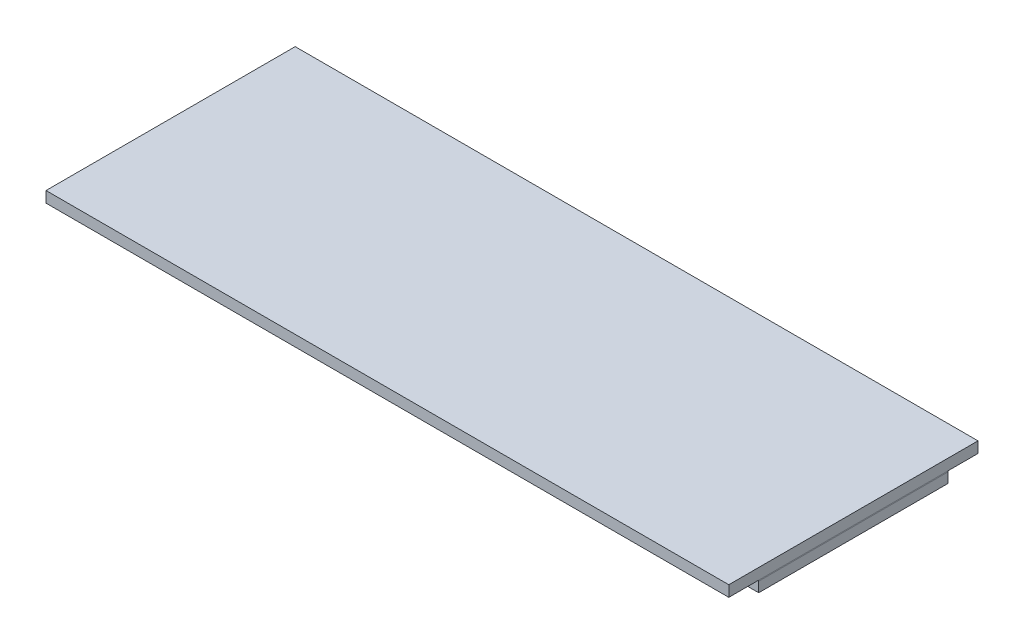
from build123d import *

# Parameters (mm, degrees)
SKETCH1_W           = 68.5
SKETCH1_H           = 25
BOSS_EXTRUDE1_DEPTH = 1.1
SKETCH2_W           = 68.5
SKETCH2_H           = 19
BOSS_EXTRUDE2_DEPTH = 0.1
SKETCH6_W           = 0.51
SKETCH6_H           = 0.5
F_16X2_LCD_DEPTH    = 1
SKETCH7_W           = 0.51
SKETCH7_H           = 0.5
DISPLAY_DEPTH       = 1
SKETCH4_W           = 68.5
SKETCH4_H           = 19
BOSS_EXTRUDE3_DEPTH = 1


with BuildPart() as part:
    # Sketch1 → Boss-Extrude1 (new body)
    with BuildSketch(Plane(origin=(0, 0, 0), x_dir=(1, 0, 0), z_dir=(0, 1, 0))):
        Rectangle(SKETCH1_W, SKETCH1_H)
    extrude(amount=BOSS_EXTRUDE1_DEPTH)


with BuildPart() as body_2:
    # Sketch2 → Boss-Extrude2 (new body)
    with BuildSketch(Plane(origin=(0, 0, 0), x_dir=(1, 0, 0), z_dir=(0, 1, 0))):
        Rectangle(SKETCH2_W, SKETCH2_H)
    extrude(amount=-BOSS_EXTRUDE2_DEPTH)

    # Sketch6 → 16x2 LCD (cut)
    with BuildSketch(Plane(origin=(0, 0, 0), x_dir=(1, 0, 0), z_dir=(0, 1, 0))):
        with Locations((-27.375, -0.65)):
            Rectangle(SKETCH6_W, SKETCH6_H)
        with Locations((-27.375, -1.2)):
            Rectangle(SKETCH6_W, SKETCH6_H)
        with Locations((-27.375, -1.75)):
            Rectangle(SKETCH6_W, SKETCH6_H)
        with Locations((-27.375, -2.3)):
            Rectangle(SKETCH6_W, SKETCH6_H)
        with Locations((-27.375, -2.85)):
            Rectangle(SKETCH6_W, SKETCH6_H)
        with Locations((-27.375, -3.4)):
            Rectangle(SKETCH6_W, SKETCH6_H)
        with Locations((-27.375, -3.95)):
            Rectangle(SKETCH6_W, SKETCH6_H)
        with Locations((-27.985, -3.95)):
            Rectangle(SKETCH6_W, SKETCH6_H)
        with Locations((-26.765, -3.95)):
            Rectangle(SKETCH6_W, SKETCH6_H)
        with Locations((-27.985, -1.2)):
            Rectangle(SKETCH6_W, SKETCH6_H)
        with Locations((-22.505, -2.85)):
            Rectangle(SKETCH6_W, SKETCH6_H)
        with Locations((-22.505, -3.4)):
            Rectangle(SKETCH6_W, SKETCH6_H)
        with Locations((-23.115, -3.95)):
            Rectangle(SKETCH6_W, SKETCH6_H)
        with Locations((-23.725, -3.95)):
            Rectangle(SKETCH6_W, SKETCH6_H)
        with Locations((-24.335, -3.95)):
            Rectangle(SKETCH6_W, SKETCH6_H)
        with Locations((-24.945, -3.4)):
            Rectangle(SKETCH6_W, SKETCH6_H)
        with Locations((-24.945, -2.85)):
            Rectangle(SKETCH6_W, SKETCH6_H)
        with Locations((-24.945, -2.3)):
            Rectangle(SKETCH6_W, SKETCH6_H)
        with Locations((-23.115, -0.65)):
            Rectangle(SKETCH6_W, SKETCH6_H)
        with Locations((-23.725, -0.65)):
            Rectangle(SKETCH6_W, SKETCH6_H)
        with Locations((-24.335, -1.2)):
            Rectangle(SKETCH6_W, SKETCH6_H)
        with Locations((-24.945, -1.75)):
            Rectangle(SKETCH6_W, SKETCH6_H)
        with Locations((-24.335, -2.3)):
            Rectangle(SKETCH6_W, SKETCH6_H)
        with Locations((-23.725, -2.3)):
            Rectangle(SKETCH6_W, SKETCH6_H)
        with Locations((-23.115, -2.3)):
            Rectangle(SKETCH6_W, SKETCH6_H)
        with Locations((-21.295, -3.95)):
            Rectangle(SKETCH6_W, SKETCH6_H)
        with Locations((-20.685, -3.4)):
            Rectangle(SKETCH6_W, SKETCH6_H)
        with Locations((-20.075, -2.85)):
            Rectangle(SKETCH6_W, SKETCH6_H)
        with Locations((-19.465, -2.3)):
            Rectangle(SKETCH6_W, SKETCH6_H)
        with Locations((-18.855, -1.75)):
            Rectangle(SKETCH6_W, SKETCH6_H)
        with Locations((-20.685, -2.3)):
            Rectangle(SKETCH6_W, SKETCH6_H)
        with Locations((-21.295, -1.75)):
            Rectangle(SKETCH6_W, SKETCH6_H)
        with Locations((-19.465, -3.4)):
            Rectangle(SKETCH6_W, SKETCH6_H)
        with Locations((-18.855, -3.95)):
            Rectangle(SKETCH6_W, SKETCH6_H)
        with Locations((-17.035, -0.65)):
            Rectangle(SKETCH6_W, SKETCH6_H)
        with Locations((-16.425, -0.65)):
            Rectangle(SKETCH6_W, SKETCH6_H)
        with Locations((-15.815, -0.65)):
            Rectangle(SKETCH6_W, SKETCH6_H)
        with Locations((-15.205, -1.2)):
            Rectangle(SKETCH6_W, SKETCH6_H)
        with Locations((-15.205, -1.75)):
            Rectangle(SKETCH6_W, SKETCH6_H)
        with Locations((-15.815, -2.3)):
            Rectangle(SKETCH6_W, SKETCH6_H)
        with Locations((-16.425, -2.85)):
            Rectangle(SKETCH6_W, SKETCH6_H)
        with Locations((-17.035, -3.4)):
            Rectangle(SKETCH6_W, SKETCH6_H)
        with Locations((-17.645, -3.95)):
            Rectangle(SKETCH6_W, SKETCH6_H)
        with Locations((-17.035, -3.95)):
            Rectangle(SKETCH6_W, SKETCH6_H)
        with Locations((-16.425, -3.95)):
            Rectangle(SKETCH6_W, SKETCH6_H)
        with Locations((-15.815, -3.95)):
            Rectangle(SKETCH6_W, SKETCH6_H)
        with Locations((-15.205, -3.95)):
            Rectangle(SKETCH6_W, SKETCH6_H)
        with Locations((-17.645, -1.2)):
            Rectangle(SKETCH6_W, SKETCH6_H)
        with Locations((-10.345, -0.65)):
            Rectangle(SKETCH6_W, SKETCH6_H)
        with Locations((-10.345, -1.2)):
            Rectangle(SKETCH6_W, SKETCH6_H)
        with Locations((-10.345, -1.75)):
            Rectangle(SKETCH6_W, SKETCH6_H)
        with Locations((-10.345, -2.3)):
            Rectangle(SKETCH6_W, SKETCH6_H)
        with Locations((-10.345, -2.85)):
            Rectangle(SKETCH6_W, SKETCH6_H)
        with Locations((-10.345, -3.4)):
            Rectangle(SKETCH6_W, SKETCH6_H)
        with Locations((-10.345, -3.95)):
            Rectangle(SKETCH6_W, SKETCH6_H)
        with Locations((-9.735, -3.95)):
            Rectangle(SKETCH6_W, SKETCH6_H)
        with Locations((-9.125, -3.95)):
            Rectangle(SKETCH6_W, SKETCH6_H)
        with Locations((-8.515, -3.95)):
            Rectangle(SKETCH6_W, SKETCH6_H)
        with Locations((-7.905, -3.95)):
            Rectangle(SKETCH6_W, SKETCH6_H)
        with Locations((-6.085, -0.65)):
            Rectangle(SKETCH6_W, SKETCH6_H)
        with Locations((-5.475, -0.65)):
            Rectangle(SKETCH6_W, SKETCH6_H)
        with Locations((-4.865, -0.65)):
            Rectangle(SKETCH6_W, SKETCH6_H)
        with Locations((-4.255, -1.2)):
            Rectangle(SKETCH6_W, SKETCH6_H)
        with Locations((-6.695, -1.2)):
            Rectangle(SKETCH6_W, SKETCH6_H)
        with Locations((-6.695, -1.75)):
            Rectangle(SKETCH6_W, SKETCH6_H)
        with Locations((-6.695, -2.3)):
            Rectangle(SKETCH6_W, SKETCH6_H)
        with Locations((-6.695, -2.85)):
            Rectangle(SKETCH6_W, SKETCH6_H)
        with Locations((-6.695, -3.4)):
            Rectangle(SKETCH6_W, SKETCH6_H)
        with Locations((-6.085, -3.95)):
            Rectangle(SKETCH6_W, SKETCH6_H)
        with Locations((-5.475, -3.95)):
            Rectangle(SKETCH6_W, SKETCH6_H)
        with Locations((-4.865, -3.95)):
            Rectangle(SKETCH6_W, SKETCH6_H)
        with Locations((-4.255, -3.4)):
            Rectangle(SKETCH6_W, SKETCH6_H)
        with Locations((-3.045, -0.65)):
            Rectangle(SKETCH6_W, SKETCH6_H)
        with Locations((-2.435, -0.65)):
            Rectangle(SKETCH6_W, SKETCH6_H)
        with Locations((-1.825, -0.65)):
            Rectangle(SKETCH6_W, SKETCH6_H)
        with Locations((-1.215, -1.2)):
            Rectangle(SKETCH6_W, SKETCH6_H)
        with Locations((-0.605, -1.75)):
            Rectangle(SKETCH6_W, SKETCH6_H)
        with Locations((-3.045, -1.2)):
            Rectangle(SKETCH6_W, SKETCH6_H)
        with Locations((-3.045, -1.75)):
            Rectangle(SKETCH6_W, SKETCH6_H)
        with Locations((-3.045, -2.3)):
            Rectangle(SKETCH6_W, SKETCH6_H)
        with Locations((-3.045, -2.85)):
            Rectangle(SKETCH6_W, SKETCH6_H)
        with Locations((-3.045, -3.4)):
            Rectangle(SKETCH6_W, SKETCH6_H)
        with Locations((-3.045, -3.95)):
            Rectangle(SKETCH6_W, SKETCH6_H)
        with Locations((-2.435, -3.95)):
            Rectangle(SKETCH6_W, SKETCH6_H)
        with Locations((-1.825, -3.95)):
            Rectangle(SKETCH6_W, SKETCH6_H)
        with Locations((-1.215, -3.4)):
            Rectangle(SKETCH6_W, SKETCH6_H)
        with Locations((-0.605, -2.85)):
            Rectangle(SKETCH6_W, SKETCH6_H)
        with Locations((-0.605, -2.3)):
            Rectangle(SKETCH6_W, SKETCH6_H)
    extrude(amount=-F_16X2_LCD_DEPTH, mode=Mode.SUBTRACT)

    # Sketch7 → Display (cut)
    with BuildSketch(Plane(origin=(0, 0, 0), x_dir=(1, 0, 0), z_dir=(0, 1, 0))):
        with Locations((4.255, -0.65)):
            Rectangle(SKETCH7_W, SKETCH7_H)
        with Locations((4.865, -0.65)):
            Rectangle(SKETCH7_W, SKETCH7_H)
        with Locations((5.475, -0.65)):
            Rectangle(SKETCH7_W, SKETCH7_H)
        with Locations((6.085, -1.2)):
            Rectangle(SKETCH7_W, SKETCH7_H)
        with Locations((6.695, -1.75)):
            Rectangle(SKETCH7_W, SKETCH7_H)
        with Locations((6.695, -2.3)):
            Rectangle(SKETCH7_W, SKETCH7_H)
        with Locations((6.695, -2.85)):
            Rectangle(SKETCH7_W, SKETCH7_H)
        with Locations((6.085, -3.4)):
            Rectangle(SKETCH7_W, SKETCH7_H)
        with Locations((5.475, -3.95)):
            Rectangle(SKETCH7_W, SKETCH7_H)
        with Locations((4.865, -3.95)):
            Rectangle(SKETCH7_W, SKETCH7_H)
        with Locations((4.255, -3.95)):
            Rectangle(SKETCH7_W, SKETCH7_H)
        with Locations((4.255, -3.4)):
            Rectangle(SKETCH7_W, SKETCH7_H)
        with Locations((4.255, -2.85)):
            Rectangle(SKETCH7_W, SKETCH7_H)
        with Locations((4.255, -2.3)):
            Rectangle(SKETCH7_W, SKETCH7_H)
        with Locations((4.255, -1.75)):
            Rectangle(SKETCH7_W, SKETCH7_H)
        with Locations((4.255, -1.2)):
            Rectangle(SKETCH7_W, SKETCH7_H)
        with Locations((9.125, -0.65)):
            Rectangle(SKETCH7_W, SKETCH7_H)
        with Locations((9.125, -1.75)):
            Rectangle(SKETCH7_W, SKETCH7_H)
        with Locations((8.515, -1.75)):
            Rectangle(SKETCH7_W, SKETCH7_H)
        with Locations((9.125, -2.3)):
            Rectangle(SKETCH7_W, SKETCH7_H)
        with Locations((9.125, -2.85)):
            Rectangle(SKETCH7_W, SKETCH7_H)
        with Locations((9.125, -3.4)):
            Rectangle(SKETCH7_W, SKETCH7_H)
        with Locations((8.515, -3.95)):
            Rectangle(SKETCH7_W, SKETCH7_H)
        with Locations((9.125, -3.95)):
            Rectangle(SKETCH7_W, SKETCH7_H)
        with Locations((9.735, -3.95)):
            Rectangle(SKETCH7_W, SKETCH7_H)
        with Locations((12.165, -1.75)):
            Rectangle(SKETCH7_W, SKETCH7_H)
        with Locations((12.775, -1.75)):
            Rectangle(SKETCH7_W, SKETCH7_H)
        with Locations((13.385, -1.75)):
            Rectangle(SKETCH7_W, SKETCH7_H)
        with Locations((12.165, -2.85)):
            Rectangle(SKETCH7_W, SKETCH7_H)
        with Locations((12.775, -2.85)):
            Rectangle(SKETCH7_W, SKETCH7_H)
        with Locations((13.385, -2.85)):
            Rectangle(SKETCH7_W, SKETCH7_H)
        with Locations((13.385, -3.95)):
            Rectangle(SKETCH7_W, SKETCH7_H)
        with Locations((12.775, -3.95)):
            Rectangle(SKETCH7_W, SKETCH7_H)
        with Locations((12.165, -3.95)):
            Rectangle(SKETCH7_W, SKETCH7_H)
        with Locations((11.555, -2.3)):
            Rectangle(SKETCH7_W, SKETCH7_H)
        with Locations((13.995, -3.4)):
            Rectangle(SKETCH7_W, SKETCH7_H)
        with Locations((11.555, -3.95)):
            Rectangle(SKETCH7_W, SKETCH7_H)
        with Locations((15.205, -4.5)):
            Rectangle(SKETCH7_W, SKETCH7_H)
        with Locations((15.205, -3.95)):
            Rectangle(SKETCH7_W, SKETCH7_H)
        with Locations((15.205, -3.4)):
            Rectangle(SKETCH7_W, SKETCH7_H)
        with Locations((15.205, -2.85)):
            Rectangle(SKETCH7_W, SKETCH7_H)
        with Locations((15.205, -2.3)):
            Rectangle(SKETCH7_W, SKETCH7_H)
        with Locations((15.205, -1.75)):
            Rectangle(SKETCH7_W, SKETCH7_H)
        with Locations((15.815, -2.3)):
            Rectangle(SKETCH7_W, SKETCH7_H)
        with Locations((16.425, -1.75)):
            Rectangle(SKETCH7_W, SKETCH7_H)
        with Locations((17.035, -1.75)):
            Rectangle(SKETCH7_W, SKETCH7_H)
        with Locations((17.645, -2.3)):
            Rectangle(SKETCH7_W, SKETCH7_H)
        with Locations((17.645, -2.85)):
            Rectangle(SKETCH7_W, SKETCH7_H)
        with Locations((15.815, -3.4)):
            Rectangle(SKETCH7_W, SKETCH7_H)
        with Locations((16.425, -3.4)):
            Rectangle(SKETCH7_W, SKETCH7_H)
        with Locations((17.035, -3.4)):
            Rectangle(SKETCH7_W, SKETCH7_H)
        with Locations((19.465, -0.65)):
            Rectangle(SKETCH7_W, SKETCH7_H)
        with Locations((20.075, -0.65)):
            Rectangle(SKETCH7_W, SKETCH7_H)
        with Locations((20.075, -1.2)):
            Rectangle(SKETCH7_W, SKETCH7_H)
        with Locations((20.075, -1.75)):
            Rectangle(SKETCH7_W, SKETCH7_H)
        with Locations((20.075, -2.3)):
            Rectangle(SKETCH7_W, SKETCH7_H)
        with Locations((20.075, -2.85)):
            Rectangle(SKETCH7_W, SKETCH7_H)
        with Locations((20.075, -3.4)):
            Rectangle(SKETCH7_W, SKETCH7_H)
        with Locations((19.465, -3.95)):
            Rectangle(SKETCH7_W, SKETCH7_H)
        with Locations((20.075, -3.95)):
            Rectangle(SKETCH7_W, SKETCH7_H)
        with Locations((20.685, -3.95)):
            Rectangle(SKETCH7_W, SKETCH7_H)
        with Locations((23.115, -1.75)):
            Rectangle(SKETCH7_W, SKETCH7_H)
        with Locations((23.725, -1.75)):
            Rectangle(SKETCH7_W, SKETCH7_H)
        with Locations((24.335, -1.75)):
            Rectangle(SKETCH7_W, SKETCH7_H)
        with Locations((24.945, -2.3)):
            Rectangle(SKETCH7_W, SKETCH7_H)
        with Locations((24.945, -2.85)):
            Rectangle(SKETCH7_W, SKETCH7_H)
        with Locations((24.945, -3.4)):
            Rectangle(SKETCH7_W, SKETCH7_H)
        with Locations((24.945, -3.95)):
            Rectangle(SKETCH7_W, SKETCH7_H)
        with Locations((24.335, -3.95)):
            Rectangle(SKETCH7_W, SKETCH7_H)
        with Locations((23.725, -3.95)):
            Rectangle(SKETCH7_W, SKETCH7_H)
        with Locations((23.115, -3.95)):
            Rectangle(SKETCH7_W, SKETCH7_H)
        with Locations((22.505, -3.4)):
            Rectangle(SKETCH7_W, SKETCH7_H)
        with Locations((23.115, -2.85)):
            Rectangle(SKETCH7_W, SKETCH7_H)
        with Locations((23.725, -2.85)):
            Rectangle(SKETCH7_W, SKETCH7_H)
        with Locations((24.335, -2.85)):
            Rectangle(SKETCH7_W, SKETCH7_H)
        with Locations((26.155, -1.75)):
            Rectangle(SKETCH7_W, SKETCH7_H)
        with Locations((26.765, -4.5)):
            Rectangle(SKETCH7_W, SKETCH7_H)
        with Locations((27.375, -4.5)):
            Rectangle(SKETCH7_W, SKETCH7_H)
        with Locations((27.985, -4.5)):
            Rectangle(SKETCH7_W, SKETCH7_H)
        with Locations((28.595, -3.95)):
            Rectangle(SKETCH7_W, SKETCH7_H)
        with Locations((28.595, -3.4)):
            Rectangle(SKETCH7_W, SKETCH7_H)
        with Locations((28.595, -2.85)):
            Rectangle(SKETCH7_W, SKETCH7_H)
        with Locations((28.595, -2.3)):
            Rectangle(SKETCH7_W, SKETCH7_H)
        with Locations((28.595, -1.75)):
            Rectangle(SKETCH7_W, SKETCH7_H)
        with Locations((27.985, -3.4)):
            Rectangle(SKETCH7_W, SKETCH7_H)
        with Locations((27.375, -3.4)):
            Rectangle(SKETCH7_W, SKETCH7_H)
        with Locations((26.765, -3.4)):
            Rectangle(SKETCH7_W, SKETCH7_H)
        with Locations((26.155, -2.85)):
            Rectangle(SKETCH7_W, SKETCH7_H)
        with Locations((26.155, -2.3)):
            Rectangle(SKETCH7_W, SKETCH7_H)
    extrude(amount=-DISPLAY_DEPTH, mode=Mode.SUBTRACT)


with BuildPart() as body_3:
    # Sketch4 → Boss-Extrude3 (new body)
    with BuildSketch(Plane.XZ.offset(0.1)):
        Rectangle(SKETCH4_W, SKETCH4_H)
    extrude(amount=BOSS_EXTRUDE3_DEPTH)


solid = Compound([part.part, body_2.part, body_3.part])
